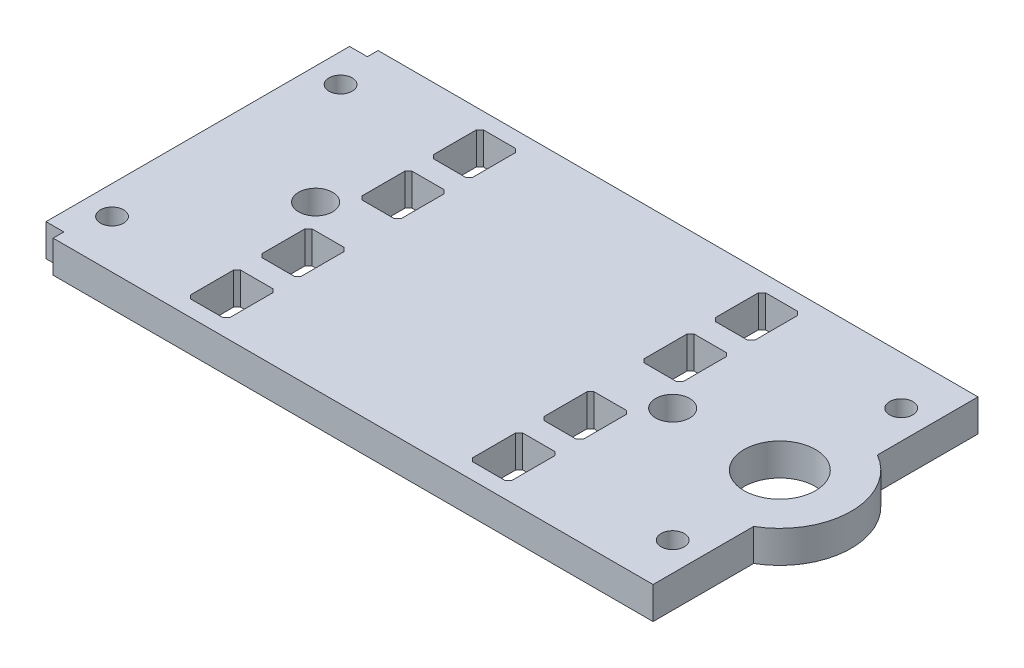
from build123d import *

# Parameters (mm, degrees)
SKETCH2_W           = 86.5
SKETCH2_H           = 45.5
BOSS_EXTRUDE1_DEPTH = 4.5
SKETCH3_R           = 1.625
SKETCH3_R_2         = 2.38125
CUT_EXTRUDE1_DEPTH  = 5.5
SKETCH4_W           = 5.5
SKETCH4_H           = 7
CUT_EXTRUDE2_DEPTH  = 5.5
CHAMFER1_SIZE       = 0.5
SKETCH5_R           = 10
BOSS_EXTRUDE2_DEPTH = 4.5
SKETCH6_R           = 5
SKETCH6_W           = 2.5
SKETCH6_H           = 1.5
CUT_EXTRUDE3_DEPTH  = 5.5


with BuildPart() as part:
    # Sketch2 → Boss-Extrude1 (new body)
    with BuildSketch(Plane(origin=(0, 0, 0), x_dir=(1, 0, 0), z_dir=(0, 1, 0))):
        with Locations((1.75, 0)):
            Rectangle(SKETCH2_W, SKETCH2_H)
    extrude(amount=BOSS_EXTRUDE1_DEPTH)

    # Sketch3 → Cut-Extrude1 (cut, through all)
    with BuildSketch(Plane(origin=(0, 4.5, 0), x_dir=(1, 0, 0), z_dir=(0, 1, 0))):
        with Locations((-37.5, -16)):
            Circle(SKETCH3_R)
        with Locations((-37.5, 16)):
            Circle(SKETCH3_R)
        with Locations((41, 16)):
            Circle(SKETCH3_R)
        with Locations((41, -16)):
            Circle(SKETCH3_R)
        with Locations((25, 0)):
            Circle(SKETCH3_R_2)
        with Locations((-25, 0)):
            Circle(SKETCH3_R_2)
    extrude(amount=-CUT_EXTRUDE1_DEPTH, mode=Mode.SUBTRACT)

    # Sketch4 → Cut-Extrude2 (cut, through all)
    with BuildSketch(Plane(origin=(0, 4.5, 0), x_dir=(1, 0, 0), z_dir=(0, 1, 0))):
        with Locations((-19.75, 7)):
            Rectangle(SKETCH4_W, SKETCH4_H)
        with Locations((-19.75, -7)):
            Rectangle(SKETCH4_W, SKETCH4_H)
        with Locations((-19.75, 17)):
            Rectangle(SKETCH4_W, SKETCH4_H)
        with Locations((-19.75, -17)):
            Rectangle(SKETCH4_W, SKETCH4_H)
    cut_extrude2 = extrude(amount=-CUT_EXTRUDE2_DEPTH, mode=Mode.SUBTRACT)

    # Mirror1: Cut-Extrude2 across plane
    add(cut_extrude2.mirror(Plane(origin=(0, 0, 0), x_dir=(0, 0, 1), z_dir=(1, 0, 0))), mode=Mode.SUBTRACT)

    # Chamfer1
    chamfer1_edges = [part.edges().sort_by_distance(p)[0] for p in [
        (22.5, 2.25, -10.5),
        (22.5, 2.25, -3.5),
        (17, 2.25, -3.5),
        (17, 2.25, -10.5),
        (22.5, 2.25, 3.5),
        (22.5, 2.25, 10.5),
        (17, 2.25, 10.5),
        (17, 2.25, 3.5),
        (22.5, 2.25, -20.5),
        (22.5, 2.25, -13.5),
        (17, 2.25, -13.5),
        (17, 2.25, -20.5),
        (22.5, 2.25, 13.5),
        (22.5, 2.25, 20.5),
        (17, 2.25, 20.5),
        (17, 2.25, 13.5),
        (-22.5, 2.25, -3.5),
        (-22.5, 2.25, -10.5),
        (-17, 2.25, -10.5),
        (-17, 2.25, -3.5),
        (-22.5, 2.25, 10.5),
        (-22.5, 2.25, 3.5),
        (-17, 2.25, 3.5),
        (-17, 2.25, 10.5),
        (-22.5, 2.25, -13.5),
        (-22.5, 2.25, -20.5),
        (-17, 2.25, -20.5),
        (-17, 2.25, -13.5),
        (-22.5, 2.25, 20.5),
        (-22.5, 2.25, 13.5),
        (-17, 2.25, 13.5),
        (-17, 2.25, 20.5),
    ]]
    chamfer(chamfer1_edges, length=CHAMFER1_SIZE)

    # Sketch5 → Boss-Extrude2 (add)
    with BuildSketch(Plane(origin=(0, 4.5, 0), x_dir=(1, 0, 0), z_dir=(0, 1, 0))):
        with Locations((40, 0)):
            Circle(SKETCH5_R)
    extrude(amount=-BOSS_EXTRUDE2_DEPTH)

    # Sketch6 → Cut-Extrude3 (cut, through all)
    with BuildSketch(Plane(origin=(0, 4.5, 0), x_dir=(1, 0, 0), z_dir=(0, 1, 0))):
        with Locations((40, 0)):
            Circle(SKETCH6_R)
        with Locations((-40.25, -22)):
            Rectangle(SKETCH6_W, SKETCH6_H)
        with Locations((-40.25, 22)):
            Rectangle(SKETCH6_W, SKETCH6_H)
    extrude(amount=-CUT_EXTRUDE3_DEPTH, mode=Mode.SUBTRACT)


solid = part.part
